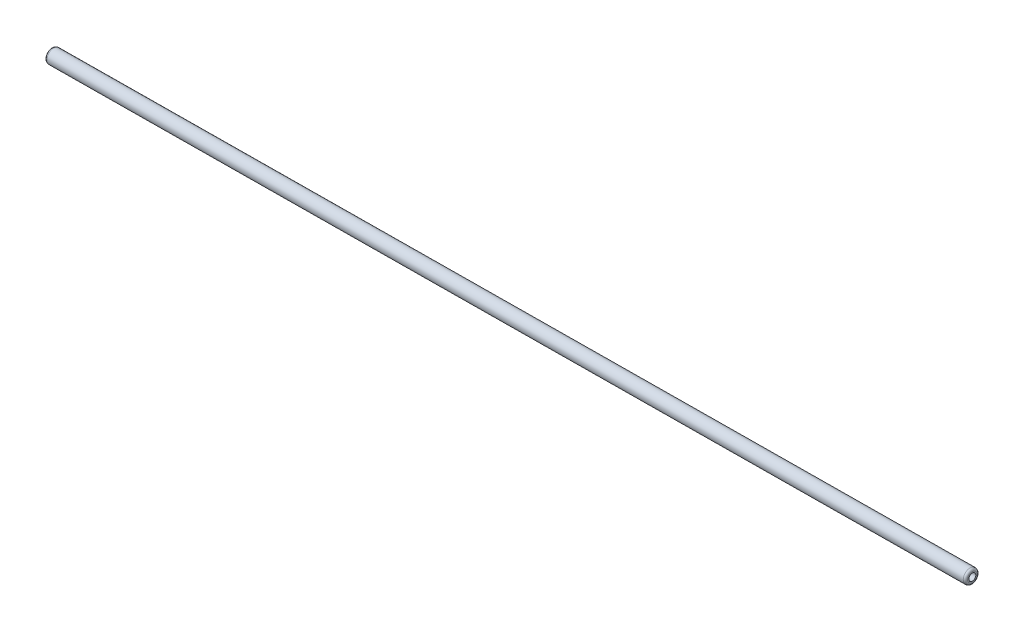
from build123d import *

# Parameters (mm, degrees)
SKETCH_1_R        = 7.9375
SKETCH_1_R_2      = 3.975
EXTRUDE_1_DEPTH   = 527.05
FILLET_1_R        = 2.5
MOVE_BODY_1_ANGLE = 90.5


with BuildPart() as part:
    # 스케치1 → 보스-돌출1 (new body, symmetric)
    with BuildSketch(Plane(origin=(0, 0, 0), x_dir=(1, 0, 0), z_dir=(0, 1, 0))):
        Circle(SKETCH_1_R)
        Circle(SKETCH_1_R_2, mode=Mode.SUBTRACT)
    extrude(amount=EXTRUDE_1_DEPTH, both=True)

    # 필렛1
    fillet_1_edges = [part.edges().sort_by_distance(p)[0] for p in [
        (-7.9375, -527.05, 0),
        (-7.9375, 527.05, 0),
    ]]
    fillet(fillet_1_edges, radius=FILLET_1_R)


with BuildPart() as part_1:
    # Move Body 1: moved
    add(part.part.rotate(Axis((0, 0, 0), (0, 0, 1)), MOVE_BODY_1_ANGLE))


solid = part_1.part
